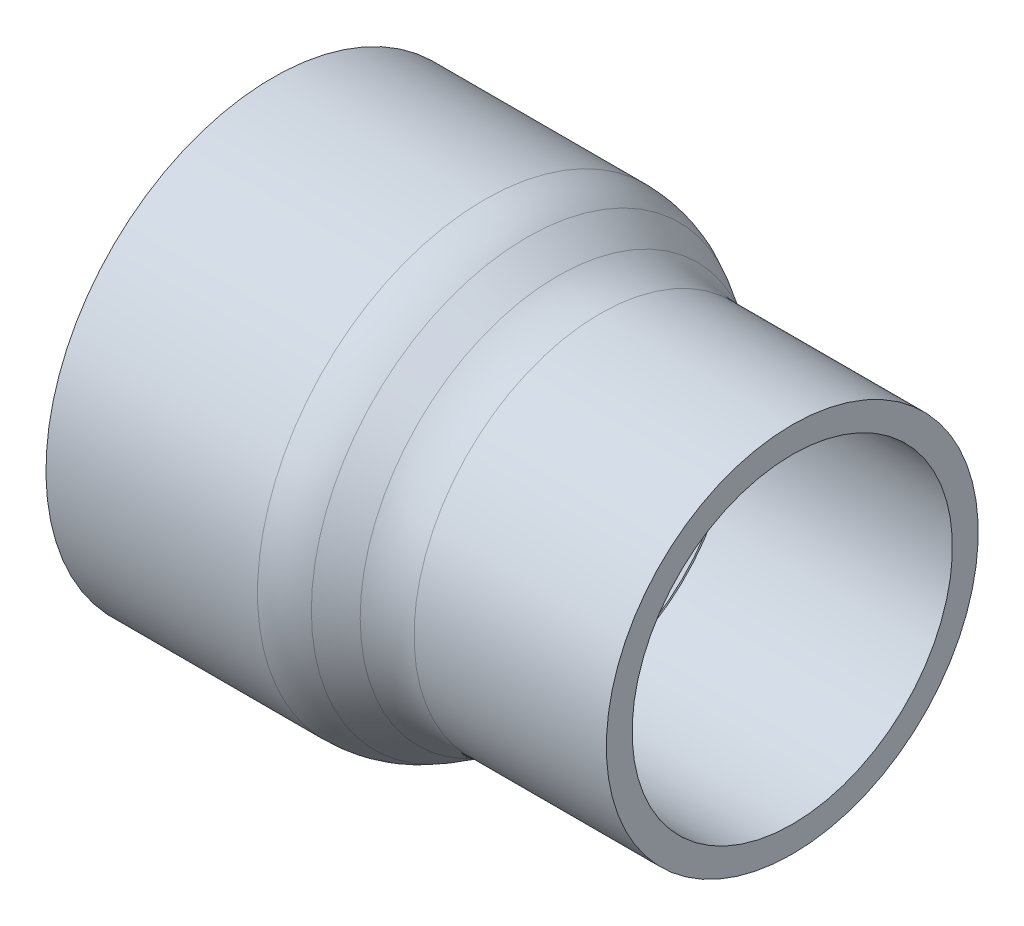
from build123d import *

# Parameters (mm, degrees)
FILLET1_R = 12.7


with BuildPart() as part:
    # Sketch1 → Revolve1 (revolve)
    with BuildSketch(Plane.XY):
        Polygon((-4.572, -30.0863), (5.999817455, -23.889705935), (6.096, -24.0538), (39.37, -24.2824), (39.37, -28.194), (6.768468807, -28.194), (-3.848398997, -34.417), (-39.37, -34.417), (-39.37, -30.3149), align=None)
    revolve(axis=Axis((-39.37, 0, 0), (1, 0, 0)))

    # Fillet1
    fillet1_edges = [part.edges().sort_by_distance(p)[0] for p in [
        (-3.848398997, 34.417, 0),
        (6.768468807, 28.194, 0),
    ]]
    fillet(fillet1_edges, radius=FILLET1_R)


solid = part.part
